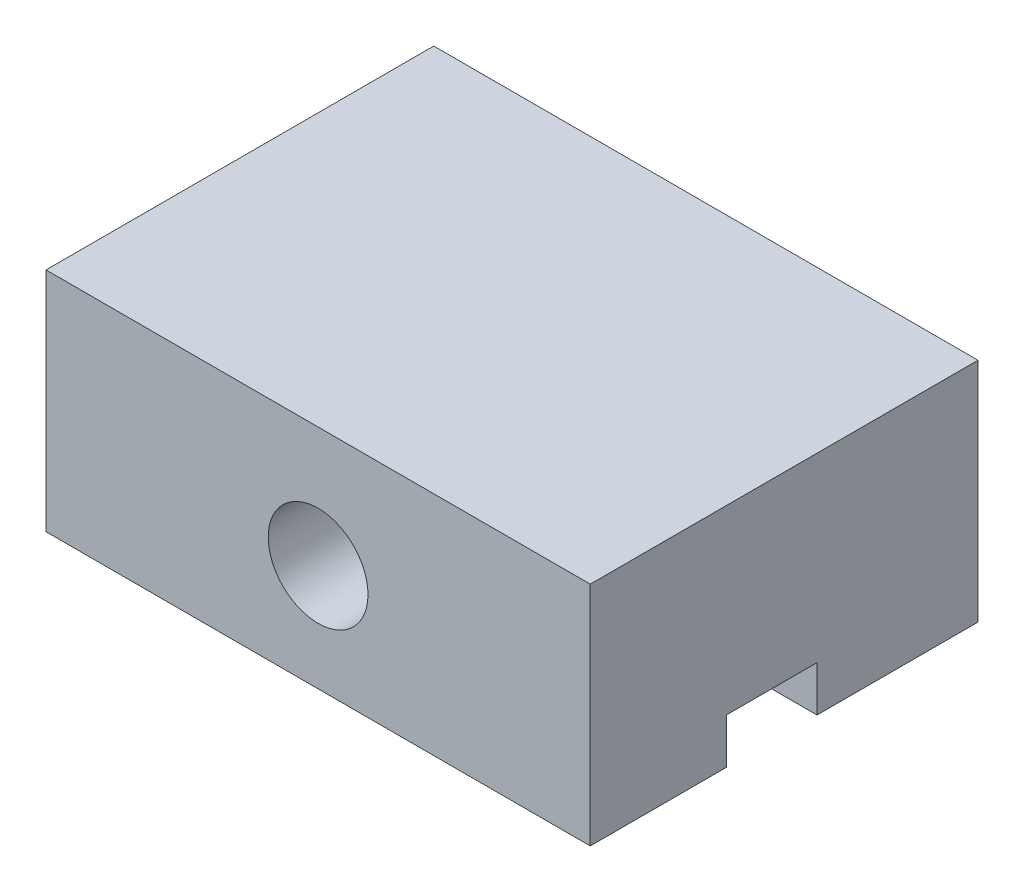
from build123d import *

# Parameters (mm, degrees)
SZKIC1_W                    = 12
SZKIC1_H                    = 5
DODANIE_WYCI_GNI_CIE1_DEPTH = 8.55
SZKIC2_R                    = 1.1
WYTNIJ_WYCI_GNI_CIE1_DEPTH  = 9.55
SZKIC3_W                    = 12
SZKIC3_H                    = 2
WYTNIJ_WYCI_GNI_CIE2_DEPTH  = 1


with BuildPart() as part:
    # Szkic1 → Dodanie-wyciągnięcie1 (new body)
    with BuildSketch(Plane.XY):
        Rectangle(SZKIC1_W, SZKIC1_H)
    extrude(amount=DODANIE_WYCI_GNI_CIE1_DEPTH)

    # Szkic2 → Wytnij-wyciągnięcie1 (cut, through all)
    with BuildSketch(Plane.XY.offset(8.55)):
        with Locations((0, -0.15)):
            Circle(SZKIC2_R)
    extrude(amount=-WYTNIJ_WYCI_GNI_CIE1_DEPTH, mode=Mode.SUBTRACT)

    # Szkic3 → Wytnij-wyciągnięcie2 (cut)
    with BuildSketch(Plane(origin=(0, -2.5, 0), x_dir=(-1, 0, 0), z_dir=(0, -1, 0))):
        with Locations((0, -4.55)):
            Rectangle(SZKIC3_W, SZKIC3_H)
    extrude(amount=-WYTNIJ_WYCI_GNI_CIE2_DEPTH, mode=Mode.SUBTRACT)


solid = part.part
